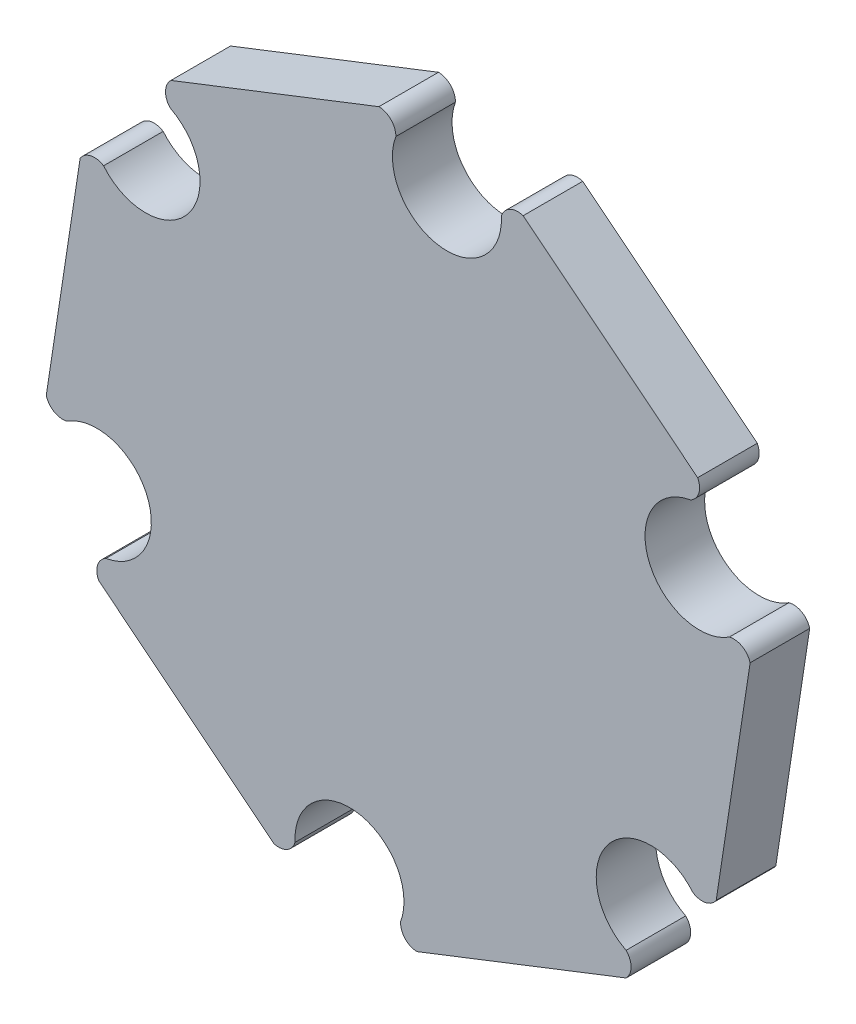
from build123d import *

# Parameters (mm, degrees)
P_IDAT_VYSUNUT_M1_DEPTH = 1.75


with BuildPart() as part:
    # Skica1 → Přidat vysunutím1 (new body)
    with BuildSketch(Plane.XY):
        with BuildLine():
            ThreePointArc((-23.51800991, -0.697818184), (-23.551279529, -0.317829699), (-23.306112267, -0.025612092))
            ThreePointArc((-23.306112267, -0.025612092), (-22.082279375, 2.134290781), (-24.446191601, 2.8924902))
            ThreePointArc((-24.446191601, 2.8924902), (-24.824522171, 2.941112168), (-25.057661359, 3.243013203))
            Line((-25.057661359, 3.243013203), (-24.063340681, 9.771553438))
            ThreePointArc((-24.063340681, 9.771553438), (-23.75089581, 9.990360015), (-23.375244308, 9.924147742))
            ThreePointArc((-23.375244308, 9.924147742), (-20.892797104, 9.944228804), (-21.418133259, 12.370536553))
            ThreePointArc((-21.418133259, 12.370536553), (-21.555999835, 12.731317514), (-21.398375562, 13.083914568))
            Line((-21.398375562, 13.083914568), (-15.289598715, 15.470565049))
            ThreePointArc((-15.289598715, 15.470565049), (-14.935362368, 15.317566791), (-14.79306555, 14.958897763))
            ThreePointArc((-14.79306555, 14.958897763), (-13.534451239, 12.819075952), (-11.695875168, 14.487184282))
            ThreePointArc((-11.695875168, 14.487184282), (-11.443098415, 14.784286161), (-11.054275505, 14.815628758))
            Line((-11.054275505, 14.815628758), (-5.929857109, 10.716094041))
            ThreePointArc((-5.929857109, 10.716094041), (-5.896587491, 10.336105556), (-6.141754752, 10.043887949))
            ThreePointArc((-6.141754752, 10.043887949), (-7.365587644, 7.883985076), (-5.001675418, 7.125785657))
            ThreePointArc((-5.001675418, 7.125785657), (-4.623928538, 7.078562418), (-4.389720717, 6.778446712))
            Line((-4.389720717, 6.778446712), (-5.385684859, 0.239115766))
            ThreePointArc((-5.385684859, 0.239115766), (-5.698895503, 0.026203976), (-6.070920244, 0.097125976))
            ThreePointArc((-6.070920244, 0.097125976), (-8.557586552, 0.076060362), (-8.03228479, -2.354579707))
            ThreePointArc((-8.03228479, -2.354579707), (-7.885616036, -2.705983653), (-8.030385679, -3.058174236))
            Line((-8.030385679, -3.058174236), (-14.178602738, -5.460233693))
            ThreePointArc((-14.178602738, -5.460233693), (-14.524317228, -5.299051786), (-14.654801469, -4.940621906))
            ThreePointArc((-14.654801469, -4.940621906), (-15.913415781, -2.800800095), (-17.751991851, -4.468908425))
            ThreePointArc((-17.751991851, -4.468908425), (-17.989793399, -4.770349614), (-18.371095594, -4.815349636))
            Line((-18.371095594, -4.815349636), (-23.51800991, -0.697818184))
        make_face()
    extrude(amount=P_IDAT_VYSUNUT_M1_DEPTH)


solid = part.part
